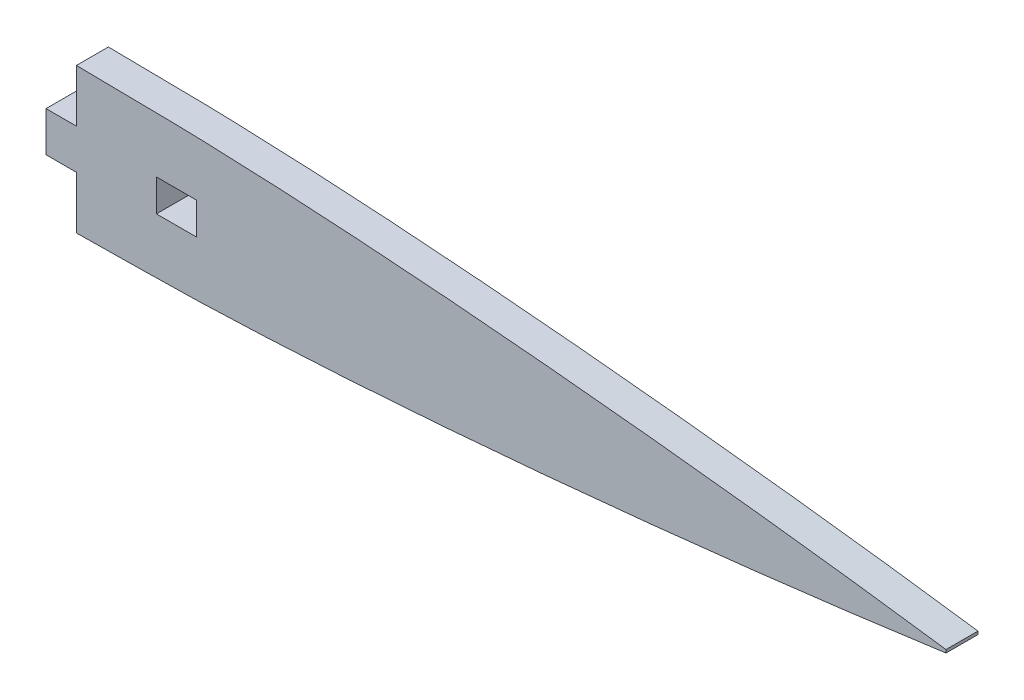
from build123d import *

# Parameters (mm, degrees)
BOSS_EXTRUDE1_DEPTH = 5.08
SKETCH3_W           = 4.826
SKETCH3_H           = 8.41502
SKETCH3_W_2         = 6.35
SKETCH3_H_2         = 5.08
CUT_EXTRUDE1_DEPTH  = 6.0800001


with BuildPart() as part:
    # Sketch2 → Boss-Extrude1 (new body)
    with BuildSketch(Plane.XY):
        with BuildLine():
            Line((190.5, 0.24003), (190.5, -0.24003))
            add(Edge.make_bspline(
                [(47.625, -11.59002), (49.21258277, -11.573232478), (52.324251607, -11.529902789), (58.609790093, -11.383526435), (66.486474066, -11.388894153), (76.012099473, -11.081769852), (85.601411445, -10.666111308), (95.189705286, -10.104719356), (104.778286225, -9.448700637), (114.303143312, -8.704754793), (123.828345261, -7.885794466), (133.353195338, -6.990482738), (142.87823509, -6.029908512), (152.403404308, -5.006647903), (161.928923416, -3.922089872), (171.454029858, -2.768063081), (180.980468385, -1.553123331), (187.325723566, -0.677879401), (190.5, -0.24003)],
                knots=[0.63243392, 0.63243392, 0.63243392, 0.63243392, 0.644639622, 0.656358033, 0.680768177, 0.705187031, 0.729619522, 0.754557907, 0.779023814, 0.803506448, 0.828005419, 0.852521438, 0.877054004, 0.901603249, 0.92617022, 0.95075713, 0.975365769, 1, 1, 1, 1], degree=3))
            Line((47.625, -11.59002), (47.625, 11.59002))
            add(Edge.make_bspline(
                [(190.5, 0.24003), (187.325723566, 0.677879401), (180.980468385, 1.553123331), (171.454029858, 2.768063081), (161.928923416, 3.922089872), (152.403404308, 5.006647903), (142.87823509, 6.029908512), (133.353195338, 6.990482738), (123.828345261, 7.885794466), (114.303143312, 8.704754793), (104.778286225, 9.448700637), (95.189705286, 10.104719356), (85.601411445, 10.666111308), (76.012099473, 11.081769852), (66.486474066, 11.388894153), (58.609790093, 11.383526435), (52.324251607, 11.529902789), (49.21258277, 11.573232478), (47.625, 11.59002)],
                knots=[0, 0, 0, 0, 0.024634231, 0.04924287, 0.07382978, 0.098396751, 0.122945996, 0.147478562, 0.171994581, 0.196493552, 0.220976186, 0.245442093, 0.270380478, 0.294812969, 0.319231823, 0.343641967, 0.355360378, 0.36756608, 0.36756608, 0.36756608, 0.36756608], degree=3))
        make_face()
    extrude(amount=BOSS_EXTRUDE1_DEPTH)

    # Sketch3 → Cut-Extrude1 (cut, through all)
    with BuildSketch(Plane(origin=(0, 0, 0), x_dir=(-1, 0, 0), z_dir=(0, 0, -1))):
        with Locations((-50.038, -7.38251)):
            Rectangle(SKETCH3_W, SKETCH3_H)
        with Locations((-50.038, 7.38251)):
            Rectangle(SKETCH3_W, SKETCH3_H)
        with Locations((-68.326, 0)):
            Rectangle(SKETCH3_W_2, SKETCH3_H_2)
    extrude(amount=-CUT_EXTRUDE1_DEPTH, mode=Mode.SUBTRACT)


solid = part.part
